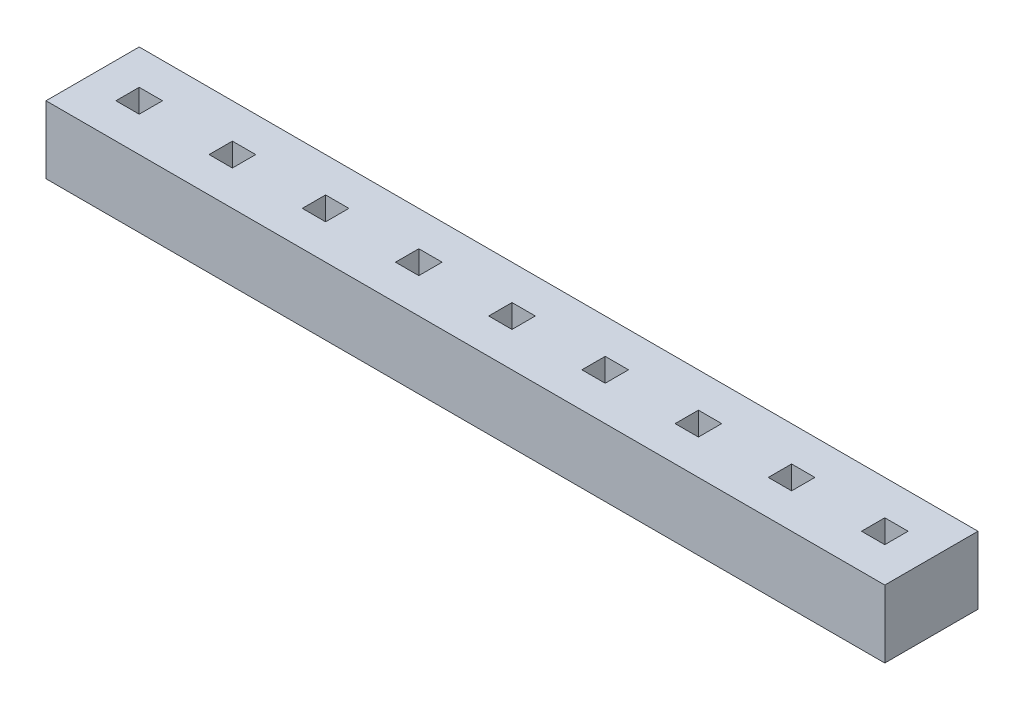
from build123d import *

# Parameters (mm, degrees)
SKETCH1_W           = 18
SKETCH1_H           = 2
BOSS_EXTRUDE1_DEPTH = 1.45
SKETCH2_W           = 0.5
SKETCH2_H           = 0.5
CUT_EXTRUDE1_DEPTH  = 1.45


with BuildPart() as part:
    # Sketch1 → Boss-Extrude1 (new body)
    with BuildSketch(Plane(origin=(0, 0, 0), x_dir=(1, 0, 0), z_dir=(0, 1, 0))):
        with Locations((9, 1)):
            Rectangle(SKETCH1_W, SKETCH1_H)
    extrude(amount=BOSS_EXTRUDE1_DEPTH)

    # Sketch2 → Cut-Extrude1 (cut)
    with BuildSketch(Plane(origin=(0, 1.45, 0), x_dir=(1, 0, 0), z_dir=(0, 1, 0))):
        with Locations((3, 1)):
            Rectangle(SKETCH2_W, SKETCH2_H)
        with Locations((1, 1)):
            Rectangle(SKETCH2_W, SKETCH2_H)
        with Locations((5, 1)):
            Rectangle(SKETCH2_W, SKETCH2_H)
        with Locations((7, 1)):
            Rectangle(SKETCH2_W, SKETCH2_H)
        with Locations((9, 1)):
            Rectangle(SKETCH2_W, SKETCH2_H)
        with Locations((11, 1)):
            Rectangle(SKETCH2_W, SKETCH2_H)
        with Locations((13, 1)):
            Rectangle(SKETCH2_W, SKETCH2_H)
        with Locations((15, 1)):
            Rectangle(SKETCH2_W, SKETCH2_H)
        with Locations((17, 1)):
            Rectangle(SKETCH2_W, SKETCH2_H)
    extrude(amount=-CUT_EXTRUDE1_DEPTH, mode=Mode.SUBTRACT)


solid = part.part
